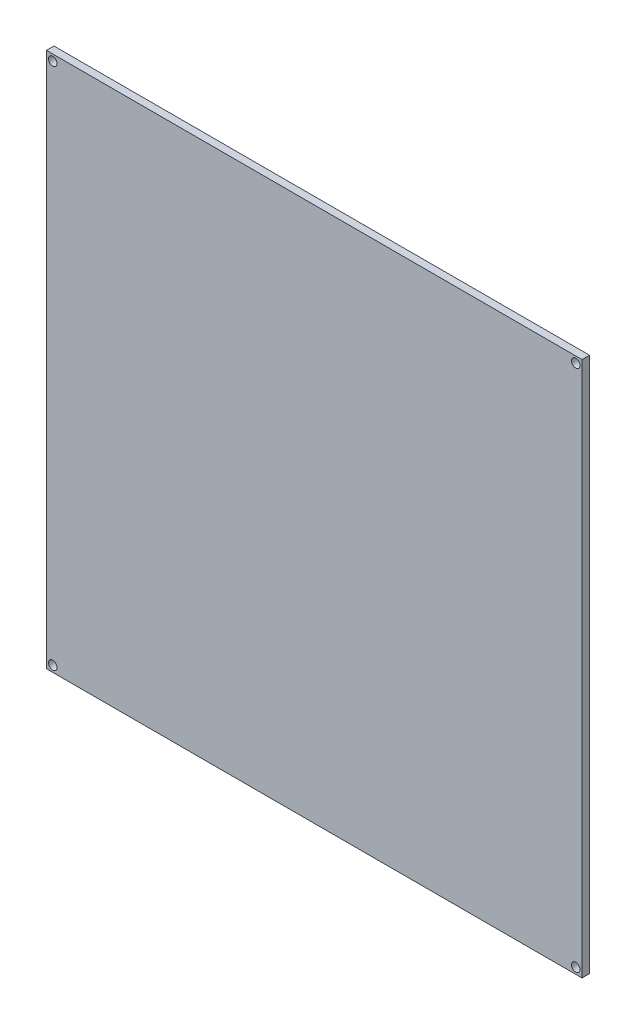
from build123d import *

# Parameters (mm, degrees)
SCHIZZO1_W                   = 214
SCHIZZO1_H                   = 214
ESTRUSIONE_ESTRUSIONE1_DEPTH = 3
FORO_PER_VITE_M3_1_D         = 3.4
FORO_PER_VITE_M3_1_DEPTH     = 3


with BuildPart() as part:
    # Schizzo1 → Estrusione-Estrusione1 (new body)
    with BuildSketch(Plane.XY):
        with Locations((-107, 107)):
            Rectangle(SCHIZZO1_W, SCHIZZO1_H)
    extrude(amount=-ESTRUSIONE_ESTRUSIONE1_DEPTH)

    # Foro per Vite M3-1
    with Locations(Plane.XY):
        with Locations((-2.5, 211.5), (-2.5, 2.5), (-211.5, 211.5), (-211.5, 2.5)):
            Hole(FORO_PER_VITE_M3_1_D / 2, depth=FORO_PER_VITE_M3_1_DEPTH)


solid = part.part
